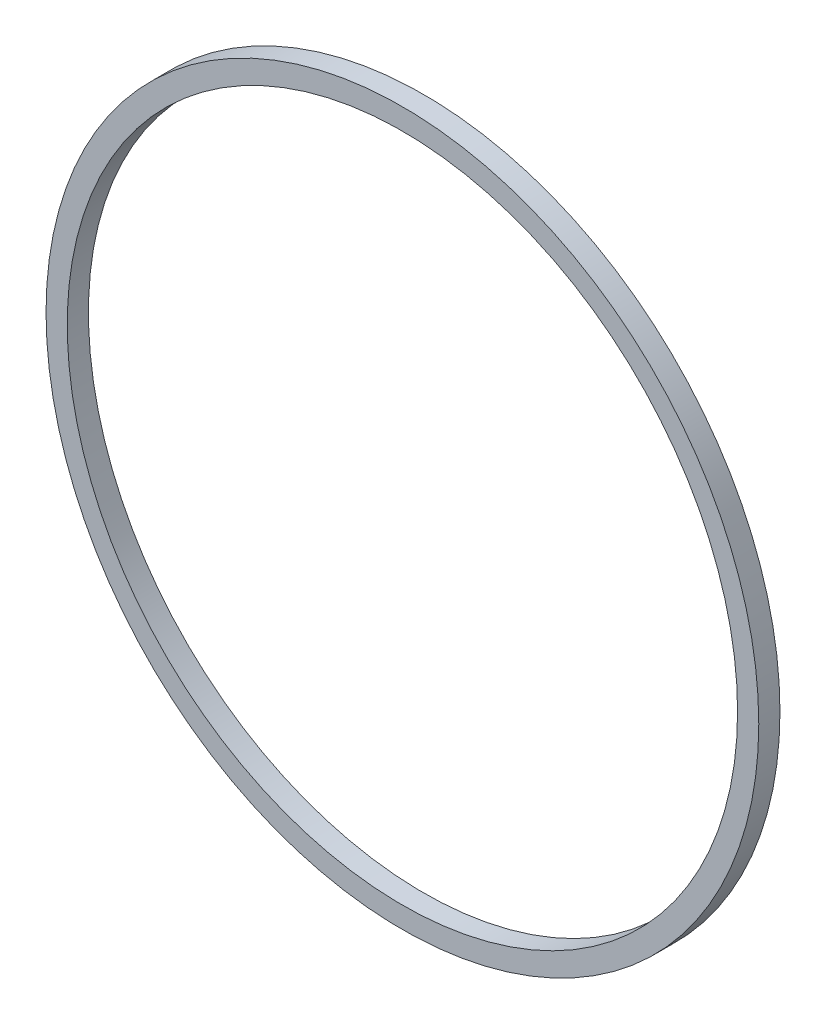
from build123d import *

# Parameters (mm, degrees)
SKETCH1_R           = 26.162
SKETCH1_R_2         = 24.60625
BOSS_EXTRUDE1_DEPTH = 1.55575


with BuildPart() as part:
    # Sketch1 → Boss-Extrude1 (new body)
    with BuildSketch(Plane.XY):
        Circle(SKETCH1_R)
        Circle(SKETCH1_R_2, mode=Mode.SUBTRACT)
    extrude(amount=BOSS_EXTRUDE1_DEPTH)


solid = part.part
